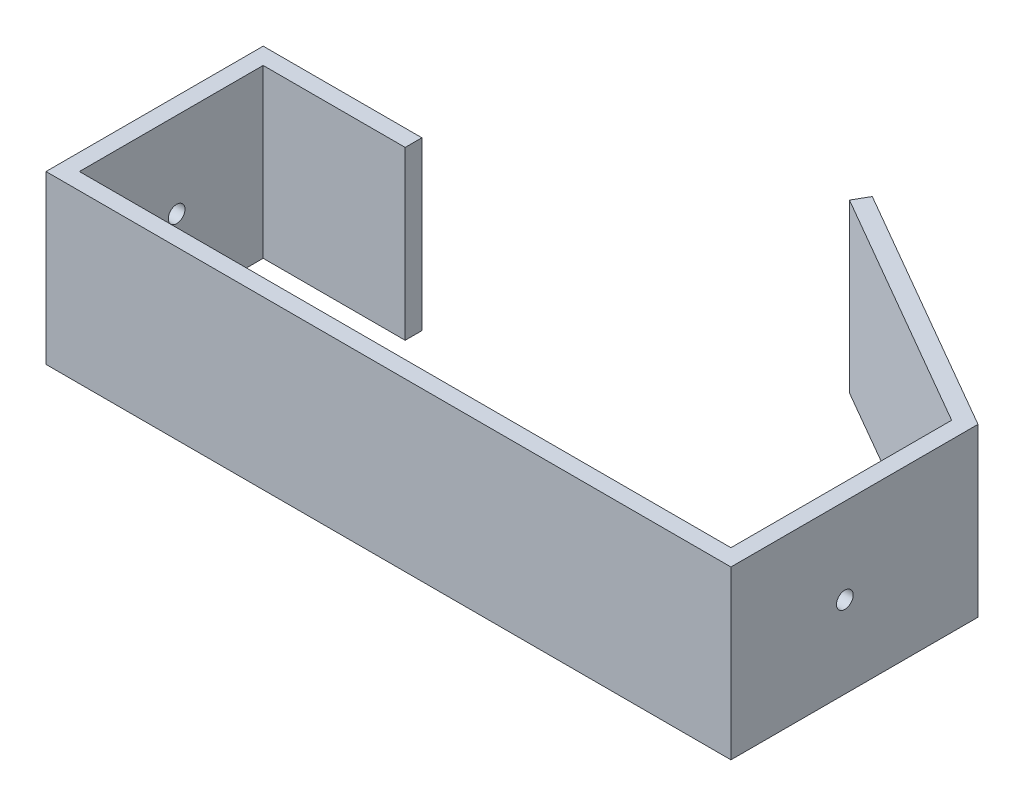
from build123d import *

# Parameters (mm, degrees)
EXTRUDE_THIN1_DEPTH = 50
SKETCH4_R           = 2.5
CUT_EXTRUDE3_DEPTH  = 206


with BuildPart() as part:
    # Sketch3 → Extrude-Thin1 (new body)
    with BuildSketch(Plane(origin=(0, 0, 0), x_dir=(1, 0, 0), z_dir=(0, 1, 0))):
        Polygon((-1.25, -2.165063509), (71.112159322, -43.943375673), (71.112159322, -110), (-123.887840678, -110), (-123.887840678, -55), (-81.387840678, -55), (-81.387840678, -50), (-128.887840678, -50), (-128.887840678, -115), (76.112159322, -115), (76.112159322, -41.056624327), (1.25, 2.165063509), align=None)
    extrude(amount=EXTRUDE_THIN1_DEPTH)

    # Sketch4 → Cut-Extrude3 (cut, through all)
    with BuildSketch(Plane(origin=(76.112159322, 0, 0), x_dir=(0, 0, -1), z_dir=(1, 0, 0))):
        with Locations((-80.909677613, 24.451666954)):
            Circle(SKETCH4_R)
    extrude(amount=-CUT_EXTRUDE3_DEPTH, mode=Mode.SUBTRACT)


solid = part.part
